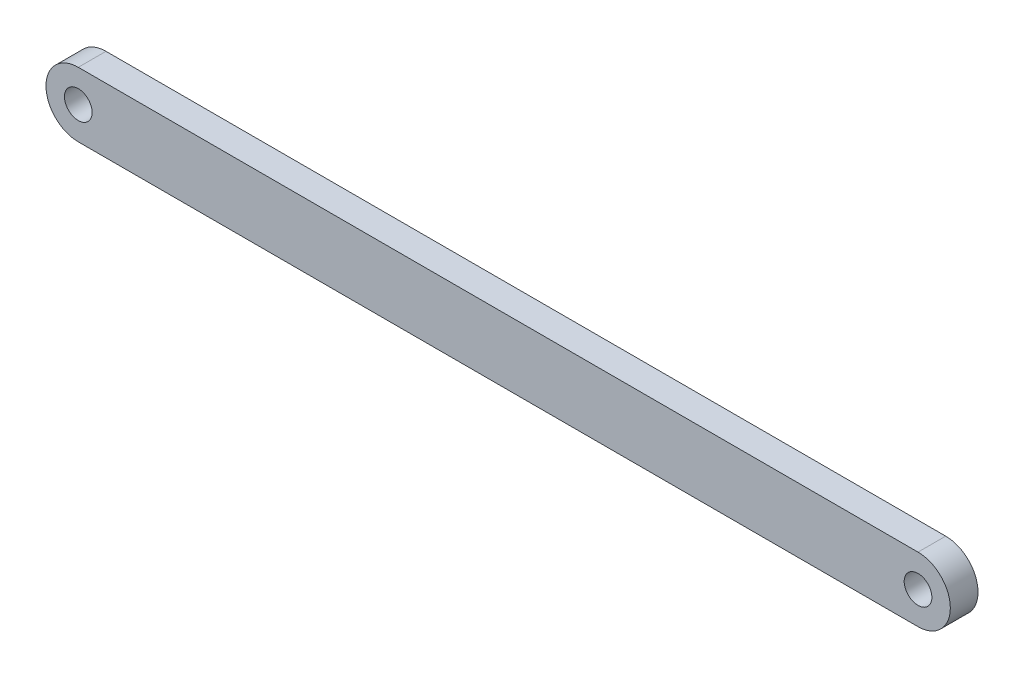
from build123d import *

# Parameters (mm, degrees)
SKETCH_1_R      = 3
EXTRUDE_1_DEPTH = 6


with BuildPart() as part:
    # 草图1 → 凸台-拉伸1 (new body)
    with BuildSketch(Plane.XY):
        with BuildLine():
            Line((0, 7), (182, 7))
            ThreePointArc((182, 7), (189, 0), (182, -7))
            Line((182, -7), (0, -7))
            ThreePointArc((0, -7), (-7, 0), (0, 7))
        make_face()
        Circle(SKETCH_1_R, mode=Mode.SUBTRACT)
        with Locations((182, 0)):
            Circle(SKETCH_1_R, mode=Mode.SUBTRACT)
    extrude(amount=EXTRUDE_1_DEPTH)


solid = part.part
